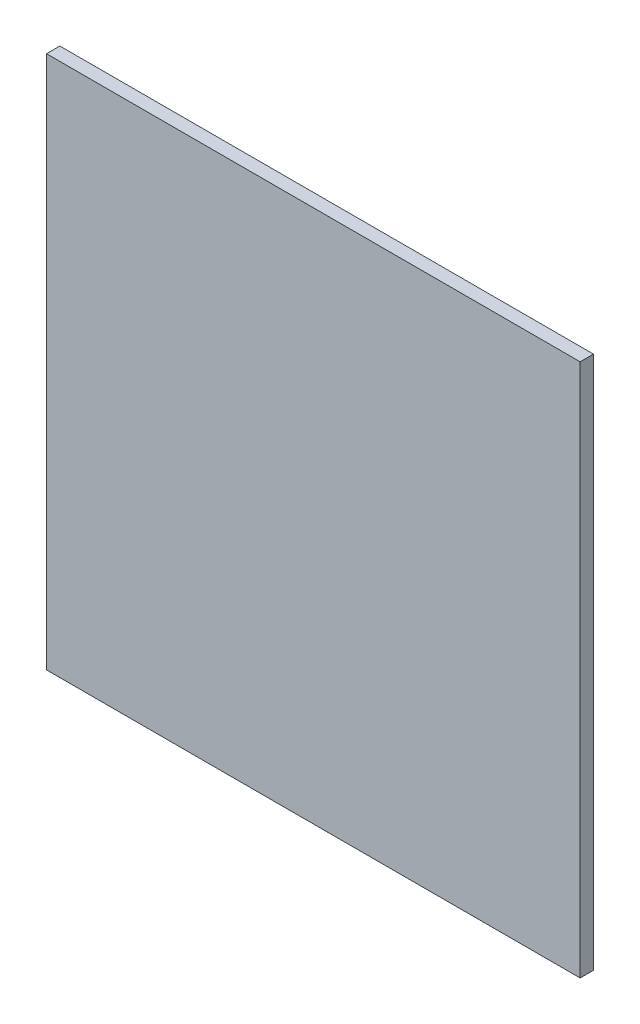
from build123d import *

# Parameters (mm, degrees)
SKETCH1_W           = 2
SKETCH1_H           = 2
BOSS_EXTRUDE1_DEPTH = 0.05


with BuildPart() as part:
    # Sketch1 → Boss-Extrude1 (new body)
    with BuildSketch(Plane.XY):
        Rectangle(SKETCH1_W, SKETCH1_H)
    extrude(amount=BOSS_EXTRUDE1_DEPTH)


solid = part.part
